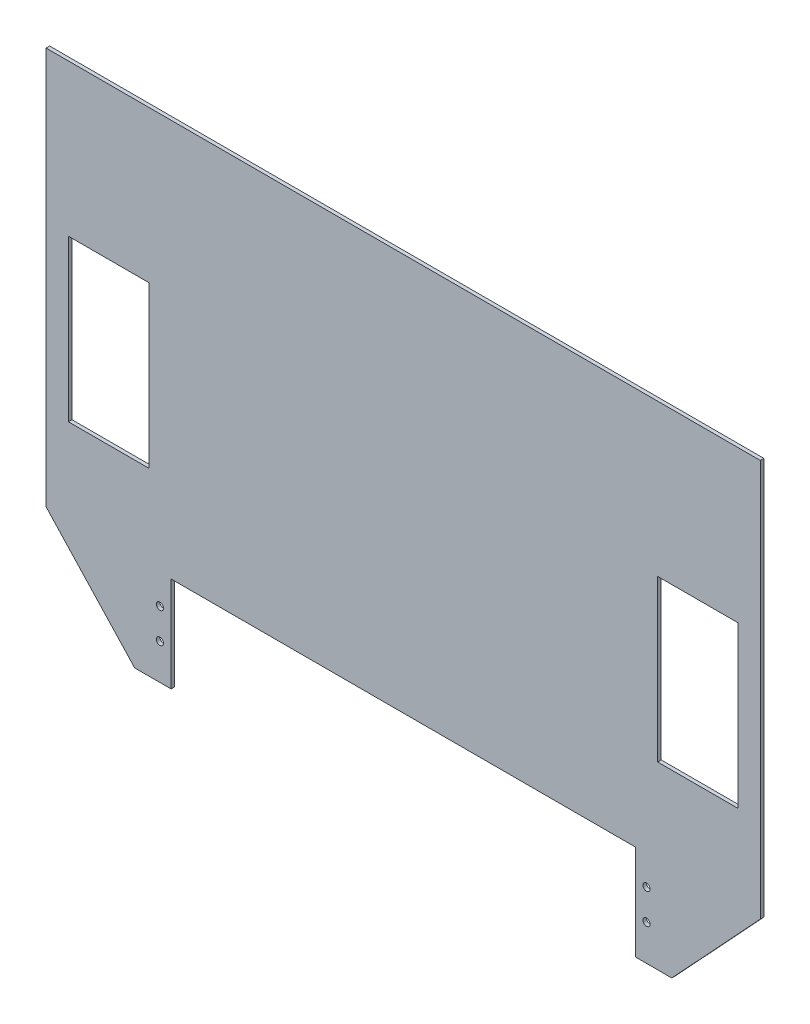
from build123d import *

# Parameters (mm, degrees)
SKETCH1_W           = 45
SKETCH1_H           = 90
BOSS_EXTRUDE1_DEPTH = 2
SKETCH2_R           = 2
CUT_EXTRUDE1_DEPTH  = 10


with BuildPart() as part:
    # Sketch1 → Boss-Extrude1 (new body)
    with BuildSketch(Plane.XY):
        Polygon((200, 0), (-200, 0), (-200, -222.5), (-150.404334867, -275.82), (-130, -275.82), (-130, -222.5), (130, -222.5), (130, -275.82), (150.404334867, -275.82), (200, -222.5), align=None)
        with Locations((-165, -130)):
            Rectangle(SKETCH1_W, SKETCH1_H, mode=Mode.SUBTRACT)
        with Locations((165, -130)):
            Rectangle(SKETCH1_W, SKETCH1_H, mode=Mode.SUBTRACT)
    extrude(amount=BOSS_EXTRUDE1_DEPTH)

    # Sketch2 → Cut-Extrude1 (cut)
    with BuildSketch(Plane.XY.offset(2)):
        with Locations((-136.25, -238.82)):
            Circle(SKETCH2_R)
        with Locations((-136.25, -255.82)):
            Circle(SKETCH2_R)
        with Locations((136.25, -255.82)):
            Circle(SKETCH2_R)
        with Locations((136.25, -238.82)):
            Circle(SKETCH2_R)
    extrude(amount=-CUT_EXTRUDE1_DEPTH, mode=Mode.SUBTRACT)


solid = part.part
